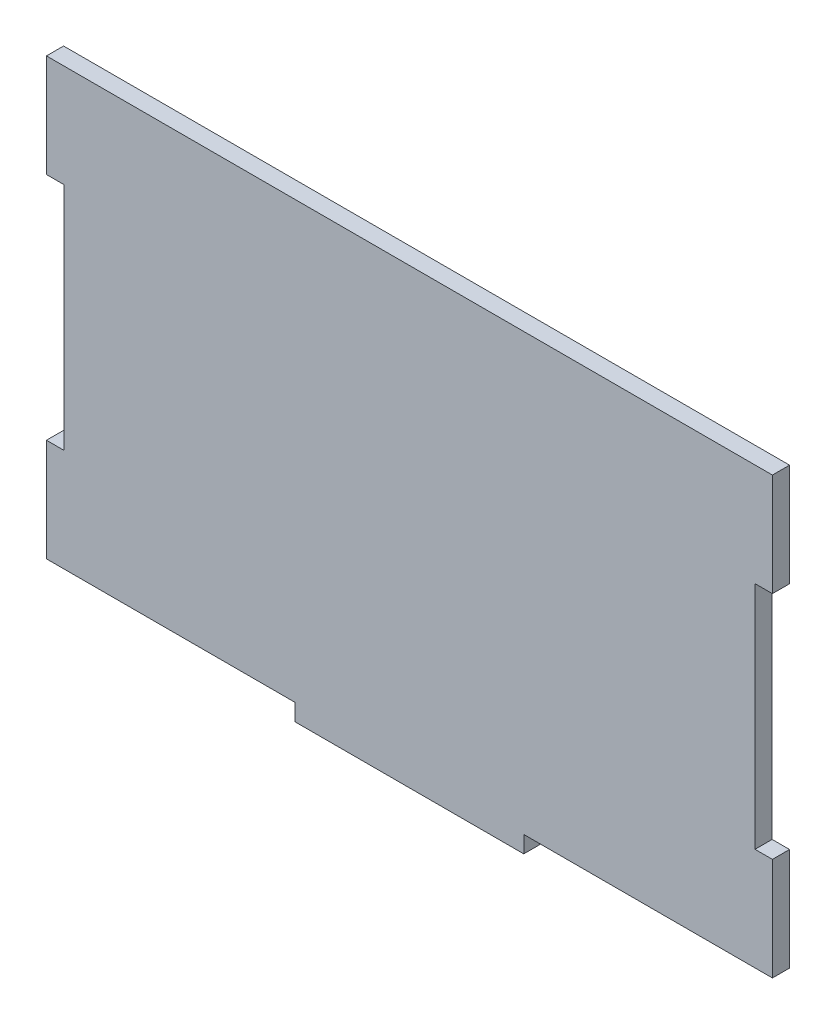
from build123d import *

# Parameters (mm, degrees)
SKETCH1_W           = 127
SKETCH1_H           = 76.2
BOSS_EXTRUDE1_DEPTH = 1.4986
SKETCH2_W           = 3.048
SKETCH2_H           = 40.254
SKETCH2_W_2         = 40.254
SKETCH2_H_2         = 2.9464
CUT_EXTRUDE1_DEPTH  = 3.9972
SKETCH3_W           = 40
SKETCH3_H           = 2.9464
BOSS_EXTRUDE2_DEPTH = 2.9972


with BuildPart() as part:
    # Sketch1 → Boss-Extrude1 (new body, symmetric)
    with BuildSketch(Plane.XY):
        Rectangle(SKETCH1_W, SKETCH1_H)
    extrude(amount=BOSS_EXTRUDE1_DEPTH, both=True)

    # Sketch2 → Cut-Extrude1 (cut, through all)
    with BuildSketch(Plane.XY.offset(1.4986)):
        with Locations((-61.976, 0)):
            Rectangle(SKETCH2_W, SKETCH2_H)
        with Locations((61.976, 0)):
            Rectangle(SKETCH2_W, SKETCH2_H)
        with Locations((0, -39.5732)):
            Rectangle(SKETCH2_W_2, SKETCH2_H_2)
    extrude(amount=-CUT_EXTRUDE1_DEPTH, mode=Mode.SUBTRACT)

    # Sketch3 → Boss-Extrude2 (add, through all)
    with BuildSketch(Plane.XY.offset(1.4986)):
        with Locations((0, -39.5732)):
            Rectangle(SKETCH3_W, SKETCH3_H)
    extrude(amount=-BOSS_EXTRUDE2_DEPTH)


solid = part.part
